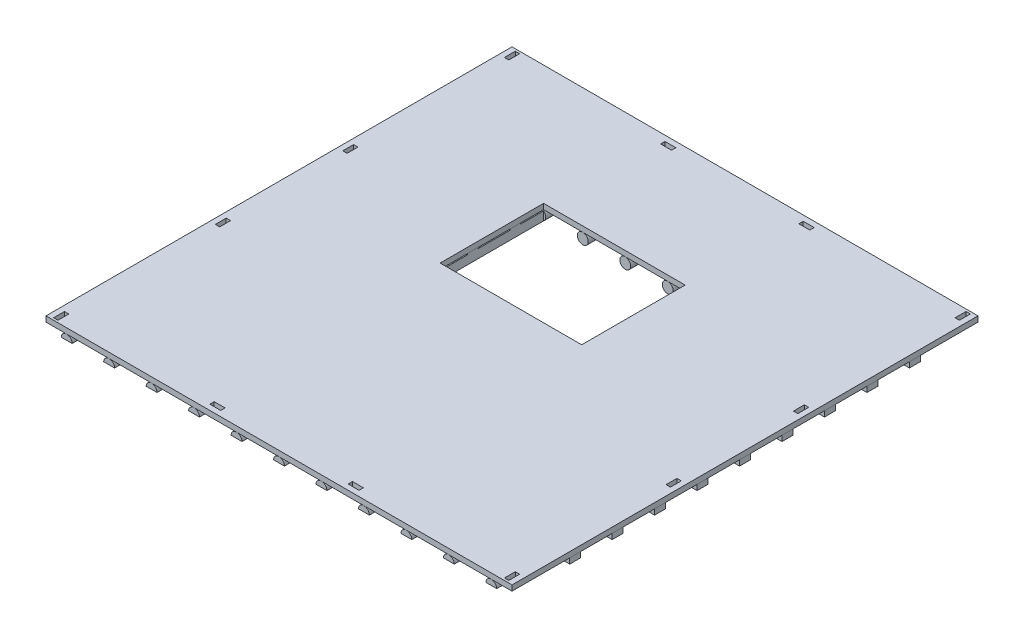
from build123d import *

# Parameters (mm, degrees)
SKETCH_1_W                       = 4280
SKETCH_1_H                       = 4280
EXTRUDE_1_DEPTH                  = 50
SKETCH_2_R                       = 50
EXTRUDE_3_DEPTH                  = 4280
SKETCH_3_W                       = 100
SKETCH_3_H                       = 100
CUT_EXTRUDE_1_DEPTH              = 140
SKETCH_4_W                       = 100
SKETCH_4_H                       = 100
CUT_EXTRUDE_2_DEPTH              = 140
PATTERN_LINEAR_2_COUNT           = 11
PATTERN_LINEAR_2_PITCH           = 390
PATTERN_LINEAR_2_2_COUNT         = 11
PATTERN_LINEAR_2_2_PITCH         = 390
SKETCH_5_W                       = 100
SKETCH_5_H                       = 30
CUT_EXTRUDE_3_DEPTH              = 4280
SKETCH_6_W                       = 100
SKETCH_6_H                       = 29.99
EXTRUDE_6_DEPTH                  = 4280
SKETCH_7_W                       = 100
SKETCH_7_H                       = 100
EXTRUDE_9_DEPTH                  = 20
SKETCH_8_W                       = 100
SKETCH_8_H                       = 100
EXTRUDE_10_DEPTH                 = 20
PATTERN_LINEAR_3_COUNT           = 9
PATTERN_LINEAR_3_PITCH           = 390
SKETCH_9_W                       = 40
SKETCH_9_H                       = 100
CUT_EXTRUDE_4_DEPTH              = 6054.66004992
PATTERN_LINEAR_4_COUNT           = 2
PATTERN_LINEAR_4_PITCH           = 4140
PATTERN_LINEAR_4_COUNT_DIR2      = 2
PATTERN_LINEAR_4_PITCH_DIR2      = 4140
SKETCH_10_W                      = 40
SKETCH_10_H                      = 100
CUT_EXTRUDE_5_DEPTH              = 6054.66004992
PATTERN_LINEAR_5_COUNT           = 2
PATTERN_LINEAR_5_PITCH           = 4140
PATTERN_LINEAR_6_COPY_1_SKETCH_W = 40
PATTERN_LINEAR_6_COPY_1_SKETCH_H = 100
PATTERN_LINEAR_6_COPY_1_DEPTH    = 6054.66004992
PATTERN_LINEAR_6_COPY_2_SKETCH_W = 40
PATTERN_LINEAR_6_COPY_2_SKETCH_H = 100
PATTERN_LINEAR_6_COPY_2_DEPTH    = 6054.66004992
SKETCH_11_W                      = 100
SKETCH_11_H                      = 40
CUT_EXTRUDE_6_DEPTH              = 100
PATTERN_LINEAR_7_COUNT           = 2
PATTERN_LINEAR_7_PITCH           = 1270
PATTERN_LINEAR_7_COUNT_DIR2      = 2
PATTERN_LINEAR_7_PITCH_DIR2      = 4140
SKETCH_12_W                      = 1300
SKETCH_12_H                      = 950
CUT_EXTRUDE_7_DEPTH              = 6055.692395159


with BuildPart() as part:
    # 草图1 → 凸台-拉伸1 (new body)
    with BuildSketch(Plane(origin=(0, 0, 0), x_dir=(1, 0, 0), z_dir=(0, 1, 0))):
        with Locations((2140, 2140)):
            Rectangle(SKETCH_1_W, SKETCH_1_H)
    extrude(amount=EXTRUDE_1_DEPTH)

    # 草图9 → 切除-拉伸4 (cut, through all)
    with BuildSketch(Plane.XZ):
        with Locations((70, -70)):
            Rectangle(SKETCH_9_W, SKETCH_9_H)
    cut_extrude_4 = extrude(amount=-CUT_EXTRUDE_4_DEPTH, mode=Mode.SUBTRACT)

    # 阵列(线性)4: Cut-Extrude 4 2 × 2
    with Locations(*[(i * PATTERN_LINEAR_4_PITCH, 0, -j * PATTERN_LINEAR_4_PITCH_DIR2) for i in range(PATTERN_LINEAR_4_COUNT) for j in range(PATTERN_LINEAR_4_COUNT_DIR2) if (i, j) != (0, 0)]):
        add(cut_extrude_4, mode=Mode.SUBTRACT)

    # 草图10 → 切除-拉伸5 (cut, through all)
    with BuildSketch(Plane.XZ):
        with Locations((70, -1555)):
            Rectangle(SKETCH_10_W, SKETCH_10_H)
    cut_extrude_5 = extrude(amount=-CUT_EXTRUDE_5_DEPTH, mode=Mode.SUBTRACT)

    # 阵列(线性)5: 切除-拉伸5 ×2
    with Locations(*[(i * PATTERN_LINEAR_5_PITCH, 0, 0) for i in range(1, PATTERN_LINEAR_5_COUNT)]):
        add(cut_extrude_5, mode=Mode.SUBTRACT)

    # 阵列(线性)6 copy 1 sketch → 阵列(线性)6 copy 1 (cut, through all)
    with BuildSketch(Plane(origin=(4140, 0, -1170), x_dir=(1, 0, 0), z_dir=(0, -1, 0))):
        with Locations((70, -1555)):
            Rectangle(PATTERN_LINEAR_6_COPY_1_SKETCH_W, PATTERN_LINEAR_6_COPY_1_SKETCH_H)
    extrude(amount=-PATTERN_LINEAR_6_COPY_1_DEPTH, mode=Mode.SUBTRACT)

    # 阵列(线性)6 copy 2 sketch → 阵列(线性)6 copy 2 (cut, through all)
    with BuildSketch(Plane(origin=(0, 0, -1170), x_dir=(1, 0, 0), z_dir=(0, -1, 0))):
        with Locations((70, -1555)):
            Rectangle(PATTERN_LINEAR_6_COPY_2_SKETCH_W, PATTERN_LINEAR_6_COPY_2_SKETCH_H)
    extrude(amount=-PATTERN_LINEAR_6_COPY_2_DEPTH, mode=Mode.SUBTRACT)

    # 草图11 → 切除-拉伸6 (cut)
    with BuildSketch(Plane.XZ):
        with Locations((1505, -70)):
            Rectangle(SKETCH_11_W, SKETCH_11_H)
    cut_extrude_6 = extrude(amount=-CUT_EXTRUDE_6_DEPTH, mode=Mode.SUBTRACT)

    # 阵列(线性)7: Cut-Extrude 6 2 × 2
    with Locations(*[(i * PATTERN_LINEAR_7_PITCH, 0, -j * PATTERN_LINEAR_7_PITCH_DIR2) for i in range(PATTERN_LINEAR_7_COUNT) for j in range(PATTERN_LINEAR_7_COUNT_DIR2) if (i, j) != (0, 0)]):
        add(cut_extrude_6, mode=Mode.SUBTRACT)


with BuildPart() as body_2:
    # 草图2 → 凸台-拉伸3 (new body)
    with BuildSketch(Plane.XY):
        with Locations((190, -50)):
            Circle(SKETCH_2_R)
    extrude_3 = extrude(amount=-EXTRUDE_3_DEPTH)

    # 草图3 → 切除-拉伸1 (cut)
    with BuildSketch(Plane.XY):
        with Locations((190, -100)):
            Rectangle(SKETCH_3_W, SKETCH_3_H)
    cut_extrude_1 = extrude(amount=-CUT_EXTRUDE_1_DEPTH, mode=Mode.SUBTRACT)

    # 草图4 → 切除-拉伸2 (cut)
    with BuildSketch(Plane(origin=(0, 0, -4280), x_dir=(-1, 0, 0), z_dir=(0, 0, -1))):
        with Locations((-190, -100)):
            Rectangle(SKETCH_4_W, SKETCH_4_H)
    cut_extrude_2 = extrude(amount=-CUT_EXTRUDE_2_DEPTH, mode=Mode.SUBTRACT)


with BuildPart() as pattern_linear_2_1:
    # 阵列(线性)2: pattern copy
    add(extrude_3.moved(Location(Vector(1, 0, 0) * (1 * PATTERN_LINEAR_2_PITCH))))


with BuildPart() as pattern_linear_2_2:
    # 阵列(线性)2: pattern copy
    add(extrude_3.moved(Location(Vector(1, 0, 0) * (2 * PATTERN_LINEAR_2_PITCH))))


with BuildPart() as pattern_linear_2_3:
    # 阵列(线性)2: pattern copy
    add(extrude_3.moved(Location(Vector(1, 0, 0) * (3 * PATTERN_LINEAR_2_PITCH))))


with BuildPart() as pattern_linear_2_4:
    # 阵列(线性)2: pattern copy
    add(extrude_3.moved(Location(Vector(1, 0, 0) * (4 * PATTERN_LINEAR_2_PITCH))))


with BuildPart() as pattern_linear_2_5:
    # 阵列(线性)2: pattern copy
    add(extrude_3.moved(Location(Vector(1, 0, 0) * (5 * PATTERN_LINEAR_2_PITCH))))


with BuildPart() as pattern_linear_2_6:
    # 阵列(线性)2: pattern copy
    add(extrude_3.moved(Location(Vector(1, 0, 0) * (6 * PATTERN_LINEAR_2_PITCH))))


with BuildPart() as pattern_linear_2_7:
    # 阵列(线性)2: pattern copy
    add(extrude_3.moved(Location(Vector(1, 0, 0) * (7 * PATTERN_LINEAR_2_PITCH))))


with BuildPart() as pattern_linear_2_8:
    # 阵列(线性)2: pattern copy
    add(extrude_3.moved(Location(Vector(1, 0, 0) * (8 * PATTERN_LINEAR_2_PITCH))))


with BuildPart() as pattern_linear_2_9:
    # 阵列(线性)2: pattern copy
    add(extrude_3.moved(Location(Vector(1, 0, 0) * (9 * PATTERN_LINEAR_2_PITCH))))


with BuildPart() as pattern_linear_2_10:
    # 阵列(线性)2: pattern copy
    add(extrude_3.moved(Location(Vector(1, 0, 0) * (10 * PATTERN_LINEAR_2_PITCH))))


with BuildPart() as pattern_linear_2_2_tool:
    # Pattern Linear 2 2: 切除-拉伸1, 切除-拉伸2 ×11
    with Locations(*[(i * PATTERN_LINEAR_2_2_PITCH, 0, 0) for i in range(1, PATTERN_LINEAR_2_2_COUNT)]):
        add(cut_extrude_1)
        add(cut_extrude_2)


with BuildPart() as pattern_linear_2_1_1:
    add(pattern_linear_2_1.part)

    # Pattern Linear 2 2: cut by pattern_linear_2_2_tool
    add(pattern_linear_2_2_tool.part, mode=Mode.SUBTRACT)


with BuildPart() as pattern_linear_2_2_1:
    add(pattern_linear_2_2.part)

    # Pattern Linear 2 2: cut by pattern_linear_2_2_tool
    add(pattern_linear_2_2_tool.part, mode=Mode.SUBTRACT)


with BuildPart() as pattern_linear_2_3_1:
    add(pattern_linear_2_3.part)

    # Pattern Linear 2 2: cut by pattern_linear_2_2_tool
    add(pattern_linear_2_2_tool.part, mode=Mode.SUBTRACT)


with BuildPart() as pattern_linear_2_4_1:
    add(pattern_linear_2_4.part)

    # Pattern Linear 2 2: cut by pattern_linear_2_2_tool
    add(pattern_linear_2_2_tool.part, mode=Mode.SUBTRACT)


with BuildPart() as pattern_linear_2_5_1:
    add(pattern_linear_2_5.part)

    # Pattern Linear 2 2: cut by pattern_linear_2_2_tool
    add(pattern_linear_2_2_tool.part, mode=Mode.SUBTRACT)


with BuildPart() as pattern_linear_2_6_1:
    add(pattern_linear_2_6.part)

    # Pattern Linear 2 2: cut by pattern_linear_2_2_tool
    add(pattern_linear_2_2_tool.part, mode=Mode.SUBTRACT)


with BuildPart() as pattern_linear_2_7_1:
    add(pattern_linear_2_7.part)

    # Pattern Linear 2 2: cut by pattern_linear_2_2_tool
    add(pattern_linear_2_2_tool.part, mode=Mode.SUBTRACT)


with BuildPart() as pattern_linear_2_8_1:
    add(pattern_linear_2_8.part)

    # Pattern Linear 2 2: cut by pattern_linear_2_2_tool
    add(pattern_linear_2_2_tool.part, mode=Mode.SUBTRACT)


with BuildPart() as pattern_linear_2_9_1:
    add(pattern_linear_2_9.part)

    # Pattern Linear 2 2: cut by pattern_linear_2_2_tool
    add(pattern_linear_2_2_tool.part, mode=Mode.SUBTRACT)


with BuildPart() as pattern_linear_2_10_1:
    add(pattern_linear_2_10.part)

    # Pattern Linear 2 2: cut by pattern_linear_2_2_tool
    add(pattern_linear_2_2_tool.part, mode=Mode.SUBTRACT)


with BuildPart() as cut_extrude_3_tool:
    # 草图5 → 切除-拉伸3 (new body)
    with BuildSketch(Plane(origin=(4280, 0, 0), x_dir=(0, 0, -1), z_dir=(1, 0, 0))):
        with Locations((580, -15)):
            Rectangle(SKETCH_5_W, SKETCH_5_H)
    extrude(amount=-CUT_EXTRUDE_3_DEPTH)


with BuildPart() as body_2_1:
    add(body_2.part)

    # 切除-拉伸3: cut by cut_extrude_3_tool
    add(cut_extrude_3_tool.part, mode=Mode.SUBTRACT)



with BuildPart() as pattern_linear_2_1_2:
    add(pattern_linear_2_1_1.part)

    # 切除-拉伸3: cut by cut_extrude_3_tool
    add(cut_extrude_3_tool.part, mode=Mode.SUBTRACT)


with BuildPart() as pattern_linear_2_2_2:
    add(pattern_linear_2_2_1.part)

    # 切除-拉伸3: cut by cut_extrude_3_tool
    add(cut_extrude_3_tool.part, mode=Mode.SUBTRACT)


with BuildPart() as pattern_linear_2_3_2:
    add(pattern_linear_2_3_1.part)

    # 切除-拉伸3: cut by cut_extrude_3_tool
    add(cut_extrude_3_tool.part, mode=Mode.SUBTRACT)


with BuildPart() as pattern_linear_2_4_2:
    add(pattern_linear_2_4_1.part)

    # 切除-拉伸3: cut by cut_extrude_3_tool
    add(cut_extrude_3_tool.part, mode=Mode.SUBTRACT)


with BuildPart() as pattern_linear_2_5_2:
    add(pattern_linear_2_5_1.part)

    # 切除-拉伸3: cut by cut_extrude_3_tool
    add(cut_extrude_3_tool.part, mode=Mode.SUBTRACT)


with BuildPart() as pattern_linear_2_6_2:
    add(pattern_linear_2_6_1.part)

    # 切除-拉伸3: cut by cut_extrude_3_tool
    add(cut_extrude_3_tool.part, mode=Mode.SUBTRACT)


with BuildPart() as pattern_linear_2_7_2:
    add(pattern_linear_2_7_1.part)

    # 切除-拉伸3: cut by cut_extrude_3_tool
    add(cut_extrude_3_tool.part, mode=Mode.SUBTRACT)


with BuildPart() as pattern_linear_2_8_2:
    add(pattern_linear_2_8_1.part)

    # 切除-拉伸3: cut by cut_extrude_3_tool
    add(cut_extrude_3_tool.part, mode=Mode.SUBTRACT)


with BuildPart() as pattern_linear_2_9_2:
    add(pattern_linear_2_9_1.part)

    # 切除-拉伸3: cut by cut_extrude_3_tool
    add(cut_extrude_3_tool.part, mode=Mode.SUBTRACT)


with BuildPart() as pattern_linear_2_10_2:
    add(pattern_linear_2_10_1.part)

    # 切除-拉伸3: cut by cut_extrude_3_tool
    add(cut_extrude_3_tool.part, mode=Mode.SUBTRACT)


with BuildPart() as body_2_2:
    add(body_2_1.part)

    add(pattern_linear_2_1_2.part)  # 凸台-拉伸6 merges 阵列(线性)2_1

    add(pattern_linear_2_2_2.part)  # 凸台-拉伸6 merges 阵列(线性)2_2

    add(pattern_linear_2_3_2.part)  # 凸台-拉伸6 merges 阵列(线性)2_3

    add(pattern_linear_2_4_2.part)  # 凸台-拉伸6 merges 阵列(线性)2_4

    add(pattern_linear_2_5_2.part)  # 凸台-拉伸6 merges 阵列(线性)2_5

    add(pattern_linear_2_6_2.part)  # 凸台-拉伸6 merges 阵列(线性)2_6

    add(pattern_linear_2_7_2.part)  # 凸台-拉伸6 merges 阵列(线性)2_7

    add(pattern_linear_2_8_2.part)  # 凸台-拉伸6 merges 阵列(线性)2_8

    add(pattern_linear_2_9_2.part)  # 凸台-拉伸6 merges 阵列(线性)2_9

    add(pattern_linear_2_10_2.part)  # 凸台-拉伸6 merges 阵列(线性)2_10
    # 草图6 → 凸台-拉伸6 (add)
    with BuildSketch(Plane(origin=(4280, 0, 0), x_dir=(0, 0, -1), z_dir=(1, 0, 0))):
        with Locations((580, -15.005)):
            Rectangle(SKETCH_6_W, SKETCH_6_H)
    extrude_6 = extrude(amount=-EXTRUDE_6_DEPTH)

    # 草图7 → 凸台-拉伸9 (add)
    with BuildSketch(Plane.XZ.offset(30)):
        with Locations((4230, -580)):
            Rectangle(SKETCH_7_W, SKETCH_7_H)
    extrude_9 = extrude(amount=EXTRUDE_9_DEPTH)

    # 草图8 → 凸台-拉伸10 (add)
    with BuildSketch(Plane.XZ.offset(30)):
        with Locations((50, -580)):
            Rectangle(SKETCH_8_W, SKETCH_8_H)
    extrude_10 = extrude(amount=EXTRUDE_10_DEPTH)

    # 阵列(线性)3: 凸台-拉伸6, 凸台-拉伸9, 凸台-拉伸10 ×9
    with Locations(*[(0, 0, -i * PATTERN_LINEAR_3_PITCH) for i in range(1, PATTERN_LINEAR_3_COUNT)]):
        add(extrude_6)
        add(extrude_9)
        add(extrude_10)


with BuildPart() as cut_extrude_7_tool:
    # 草图12 → 切除-拉伸7 (new, through all)
    with BuildSketch(Plane(origin=(0, 50, 0), x_dir=(1, 0, 0), z_dir=(0, 1, 0))):
        with Locations((2040, 2705)):
            Rectangle(SKETCH_12_W, SKETCH_12_H)
    extrude(amount=-CUT_EXTRUDE_7_DEPTH)


with BuildPart() as part_1:
    add(part.part)

    # 切除-拉伸7: cut by cut_extrude_7_tool
    add(cut_extrude_7_tool.part, mode=Mode.SUBTRACT)


with BuildPart() as body_2_3:
    add(body_2_2.part)

    # 切除-拉伸7: cut by cut_extrude_7_tool
    add(cut_extrude_7_tool.part, mode=Mode.SUBTRACT)


solid = Compound([part_1.part, body_2_3.part])
